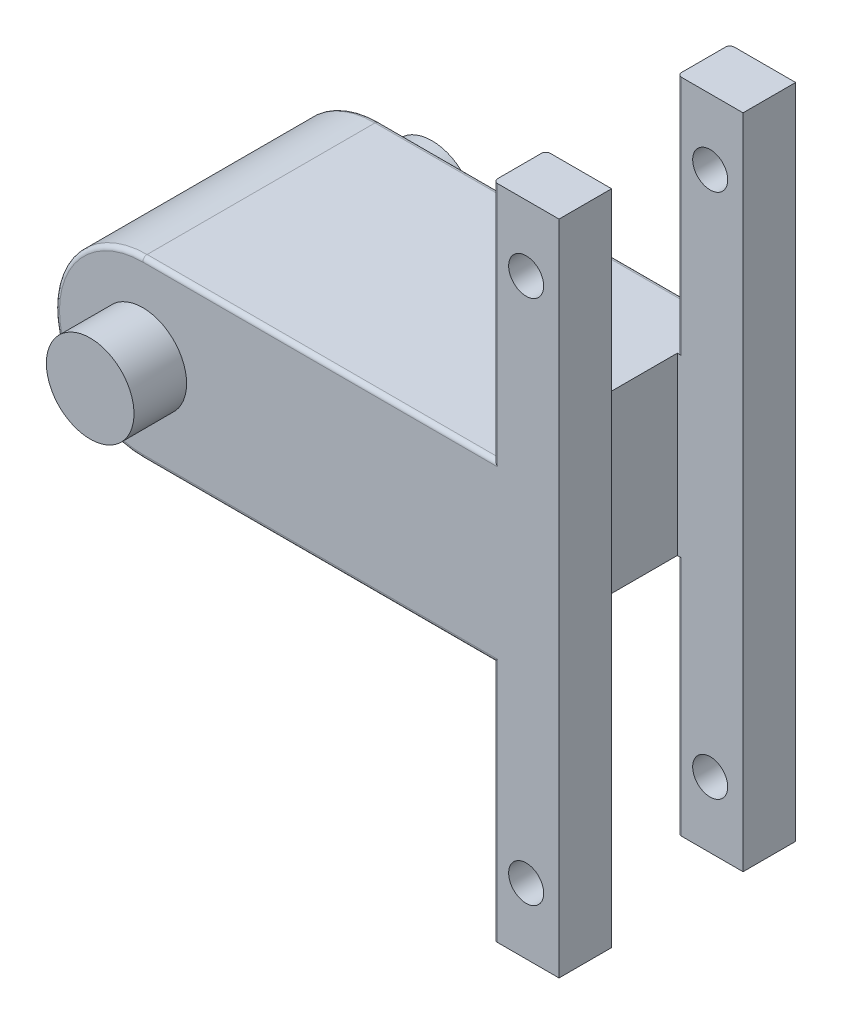
from build123d import *

# Parameters (mm, degrees)
SKETCH1_R           = 4
BOSS_EXTRUDE1_DEPTH = 54
SKETCH2_R           = 10
BOSS_EXTRUDE2_DEPTH = 12
SKETCH3_W           = 15
SKETCH3_H           = 30
CUT_EXTRUDE1_DEPTH  = 150
FILLET1_R           = 1


with BuildPart() as part:
    # Sketch1 → Boss-Extrude1 (new body)
    with BuildSketch(Plane.XY):
        with BuildLine():
            Line((0, 75), (0, 20))
            Line((0, 20), (-80, 20))
            ThreePointArc((-80, 20), (-100, 0), (-80, -20))
            Line((-80, -20), (0, -20))
            Line((0, -20), (0, -75))
            Line((0, -75), (15, -75))
            Line((15, -75), (15, 75))
            Line((15, 75), (0, 75))
        make_face()
        with Locations((7.5, 60)):
            Circle(SKETCH1_R, mode=Mode.SUBTRACT)
        with Locations((7.5, -60)):
            Circle(SKETCH1_R, mode=Mode.SUBTRACT)
    extrude(amount=BOSS_EXTRUDE1_DEPTH)

    # Sketch2 → Boss-Extrude2 (add)
    with BuildSketch(Plane(origin=(0, 0, 0), x_dir=(-1, 0, 0), z_dir=(0, 0, -1))):
        with Locations((80, 0)):
            Circle(SKETCH2_R)
    boss_extrude2 = extrude(amount=BOSS_EXTRUDE2_DEPTH)

    # Mirror1: Boss-Extrude2 across plane
    add(boss_extrude2.mirror(Plane.XY.offset(27)))

    # Sketch3 → Cut-Extrude1 (cut)
    with BuildSketch(Plane(origin=(0, 75, 0), x_dir=(1, 0, 0), z_dir=(0, 1, 0))):
        with Locations((7.5, -27)):
            Rectangle(SKETCH3_W, SKETCH3_H)
    extrude(amount=-CUT_EXTRUDE1_DEPTH, mode=Mode.SUBTRACT)

    # Fillet1
    fillet1_edges = [part.edges().sort_by_distance(p)[0] for p in [
        (0, -47.5, 0),
        (-40, -20, 0),
        (-100, 0, 0),
        (0, -47.5, 54),
        (0, 47.5, 54),
        (-40, 20, 54),
        (-100, 0, 54),
        (0, -47.5, 42),
        (0, 47.5, 42),
        (0, -47.5, 12),
        (0, 47.5, 12),
        (-40, 20, 0),
        (-40, -20, 54),
        (0, 47.5, 0),
    ]]
    fillet(fillet1_edges, radius=FILLET1_R)


solid = part.part
